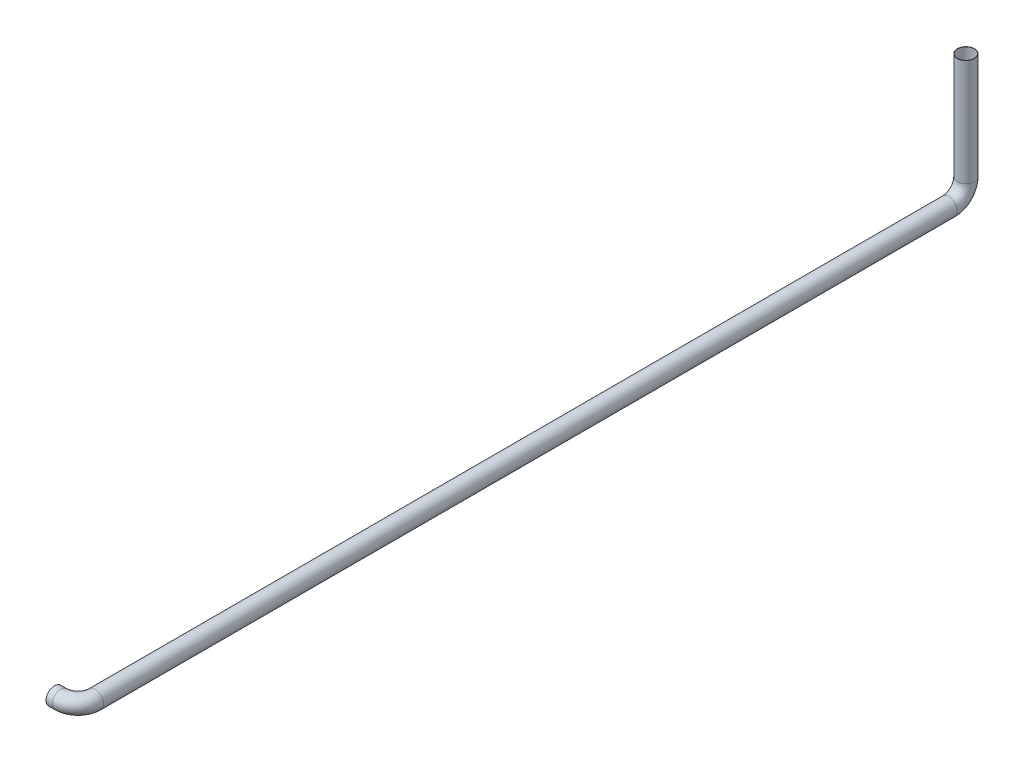
from build123d import *

# Parameters (mm, degrees)
SWEEP_THIN1_PROFILE_R   = 30
SWEEP_THIN1_PROFILE_R_2 = 29


with BuildPart() as part:
    # Sweep-Thin1: sweep along a curve in space
    with BuildLine() as sweep_thin1_path:
        Line((-28941.617683291, -14739.133353414, 39013.890196057), (-28941.617683291, -15112.013633935, 39013.890196057))
        ThreePointArc((-28941.617683291, -15172.013633935, 39073.890196057), (-28941.617683291, -15154.440040806, 39031.463789186), (-28941.617683291, -15112.013633935, 39013.890196057))
        Line((-28941.617683291, -15172.013633935, 39073.890196057), (-28941.617683291, -15172.013633935, 42061.700196057))
        ThreePointArc((-28941.617683291, -15172.013633935, 42061.700196057), (-28959.19127642, -15172.013633935, 42104.126602928), (-29001.617683291, -15172.013633935, 42121.700196057))
        Line((-29001.617683291, -15172.013633935, 42121.700196057), (-29023.421998341, -15172.013633935, 42121.700196057))
    # Sweep-Thin1 profile (on start of the path) → Sweep-Thin1 (sweep)
    with BuildSketch(Plane(origin=(-28941.617683291, -14739.133353414, 39013.890196057), x_dir=(0, 0, -1), z_dir=(0, -1, 0))):
        Circle(SWEEP_THIN1_PROFILE_R)
        Circle(SWEEP_THIN1_PROFILE_R_2, mode=Mode.SUBTRACT)
    sweep(path=sweep_thin1_path.line)


solid = part.part
